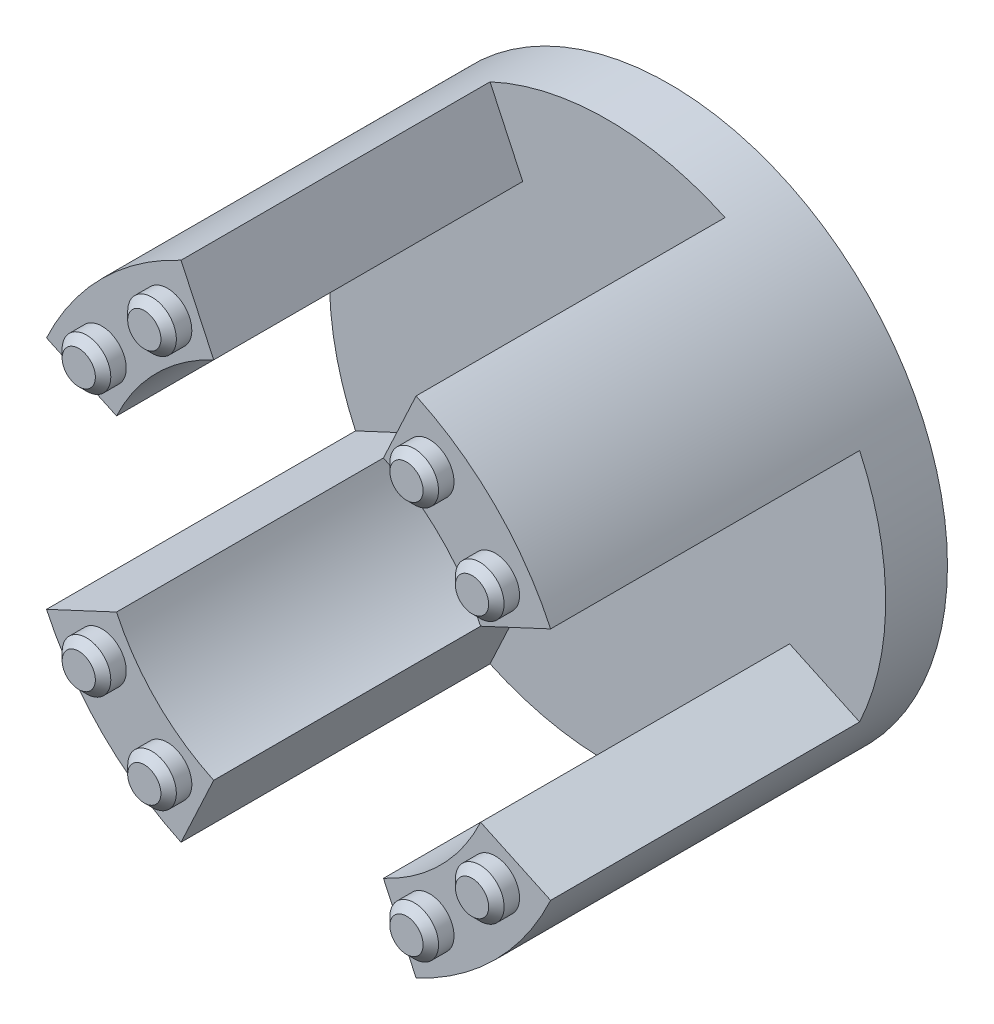
from build123d import *

# Parameters (mm, degrees)
SKETCH_1_R               = 18
SKETCH_1_R_2             = 1
EXTRUDE_1_DEPTH          = 4
EXTRUDE_2_DEPTH          = 20
PATTERN_CIRCULAR_1_COUNT = 4
SKETCH_3_R               = 1.575
EXTRUDE_3_DEPTH          = 1.5
PATTERN_CIRCULAR_2_COUNT = 4
SKETCH_4_R               = 6.25
CUT_EXTRUDE_1_DEPTH      = 2
CHAMFER_1_SIZE           = 0.5


with BuildPart() as part:
    # ｽｹｯﾁ1 → ﾎﾞｽ - 押し出し1 (new body)
    with BuildSketch(Plane.XY):
        Circle(SKETCH_1_R)
        with Locations((0, 3)):
            Circle(SKETCH_1_R_2, mode=Mode.SUBTRACT)
        with Locations((3, 0)):
            Circle(SKETCH_1_R_2, mode=Mode.SUBTRACT)
        with Locations((0, -3)):
            Circle(SKETCH_1_R_2, mode=Mode.SUBTRACT)
        with Locations((-3, 0)):
            Circle(SKETCH_1_R_2, mode=Mode.SUBTRACT)
    extrude(amount=EXTRUDE_1_DEPTH)

    # ｽｹｯﾁ2 → ﾎﾞｽ - 押し出し2 (add)
    with BuildSketch(Plane.XY.offset(4)):
        with BuildLine():
            Line((16.313540167, -7.607128711), (11.782001231, -5.494037403))
            ThreePointArc((11.782001231, -5.494037403), (9.192388155, -9.192388155), (5.494037403, -11.782001231))
            Line((5.494037403, -11.782001231), (7.607128711, -16.313540167))
            ThreePointArc((7.607128711, -16.313540167), (12.727922061, -12.727922061), (16.313540167, -7.607128711))
        make_face()
    extrude_2 = extrude(amount=EXTRUDE_2_DEPTH)

    # 円形ﾊﾟﾀｰﾝ1: ﾎﾞｽ - 押し出し2 ×4 about axis
    pattern_circular_1_axis = Axis((0, 0, 24), (0, 0, -1))
    for i in range(1, PATTERN_CIRCULAR_1_COUNT):
        add(extrude_2.rotate(pattern_circular_1_axis, i * 360 / PATTERN_CIRCULAR_1_COUNT))

    # ｽｹｯﾁ3 → ﾎﾞｽ - 押し出し3 (add)
    with BuildSketch(Plane.XY.offset(24)):
        with Locations((8.485281374, 12.727922061)):
            Circle(SKETCH_3_R)
        with Locations((12.727922061, 8.485281374)):
            Circle(SKETCH_3_R)
    extrude_3 = extrude(amount=EXTRUDE_3_DEPTH)

    # 円形ﾊﾟﾀｰﾝ2: ﾎﾞｽ - 押し出し3 ×4 about axis
    pattern_circular_2_axis = Axis((0, 0, 0), (0, 0, 1))
    for i in range(1, PATTERN_CIRCULAR_2_COUNT):
        add(extrude_3.rotate(pattern_circular_2_axis, i * 360 / PATTERN_CIRCULAR_2_COUNT))

    # ｽｹｯﾁ4 → ｶｯﾄ - 押し出し1 (cut)
    with BuildSketch(Plane(origin=(0, 0, 0), x_dir=(-1, 0, 0), z_dir=(0, 0, -1))):
        Circle(SKETCH_4_R)
    extrude(amount=-CUT_EXTRUDE_1_DEPTH, mode=Mode.SUBTRACT)

    # 面取り1
    chamfer_1_edges = [part.edges().sort_by_distance(p)[0] for p in [
        (6.910281374, 12.727922061, 25.5),
        (11.152922061, 8.485281374, 25.5),
        (12.727922061, -6.910281374, 25.5),
        (8.485281374, -11.152922061, 25.5),
        (-6.910281374, -12.727922061, 25.5),
        (-11.152922061, -8.485281374, 25.5),
        (-12.727922061, 6.910281374, 25.5),
        (-8.485281374, 11.152922061, 25.5),
    ]]
    chamfer(chamfer_1_edges, length=CHAMFER_1_SIZE)


solid = part.part
